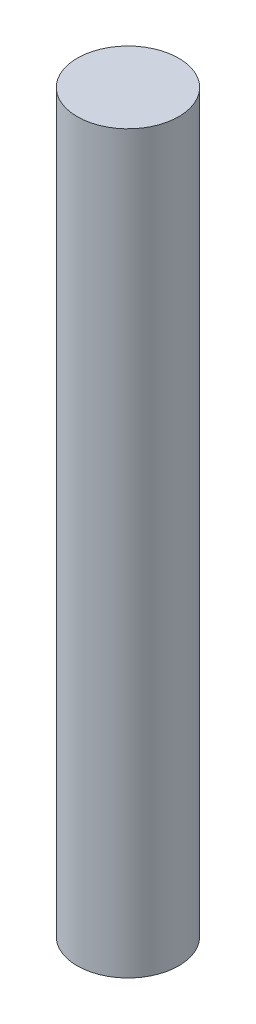
from build123d import *

# Parameters (mm, degrees)
SKETCH1_R           = 1
BOSS_EXTRUDE1_DEPTH = 14.5


with BuildPart() as part:
    # Sketch1 → Boss-Extrude1 (new body)
    with BuildSketch(Plane(origin=(0, 0, 0), x_dir=(1, 0, 0), z_dir=(0, 1, 0))):
        Circle(SKETCH1_R)
    extrude(amount=BOSS_EXTRUDE1_DEPTH)


solid = part.part
